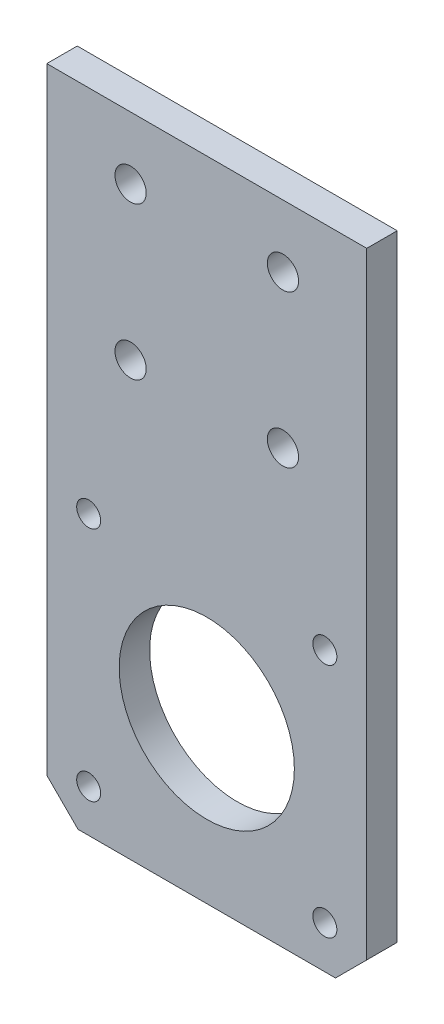
from build123d import *

# Parameters (mm, degrees)
CROQUIS1_W              = 42
CROQUIS1_H              = 85
CROQUIS1_R              = 2.05
CROQUIS1_R_2            = 2.55
SALIENTE_EXTRUIR1_DEPTH = 4
CROQUIS5_R              = 11.5
CROQUIS5_R_2            = 1.575
CORTAR_EXTRUIR2_DEPTH   = 5
CHAFL_N1_SIZE           = 4.1


with BuildPart() as part:
    # Croquis1 → Saliente-Extruir1 (new body)
    with BuildSketch(Plane.XY):
        with Locations((21, 42.5)):
            Rectangle(CROQUIS1_W, CROQUIS1_H)
        with Locations((11, 76.8)):
            Circle(CROQUIS1_R, mode=Mode.SUBTRACT)
        with Locations((31, 76.8)):
            Circle(CROQUIS1_R, mode=Mode.SUBTRACT)
        with Locations((31, 56.8)):
            Circle(CROQUIS1_R, mode=Mode.SUBTRACT)
        with Locations((11, 56.8)):
            Circle(CROQUIS1_R, mode=Mode.SUBTRACT)
        with Locations((21, 21.08)):
            Circle(CROQUIS1_R_2, mode=Mode.SUBTRACT)
    extrude(amount=SALIENTE_EXTRUIR1_DEPTH)

    # Croquis5 → Cortar-Extruir2 (cut, through all)
    with BuildSketch(Plane.XY.offset(4)):
        with Locations((21, 21.08)):
            Circle(CROQUIS5_R)
        with Locations((5.5, 36.58)):
            Circle(CROQUIS5_R_2)
        with Locations((36.5, 36.58)):
            Circle(CROQUIS5_R_2)
        with Locations((36.5, 5.58)):
            Circle(CROQUIS5_R_2)
        with Locations((5.5, 5.58)):
            Circle(CROQUIS5_R_2)
    extrude(amount=-CORTAR_EXTRUIR2_DEPTH, mode=Mode.SUBTRACT)

    # Chaflán1
    chafl_n1_edges = [part.edges().sort_by_distance(p)[0] for p in [
        (42, 0, 2),
        (0, 0, 2),
    ]]
    chamfer(chafl_n1_edges, length=CHAFL_N1_SIZE)


solid = part.part
